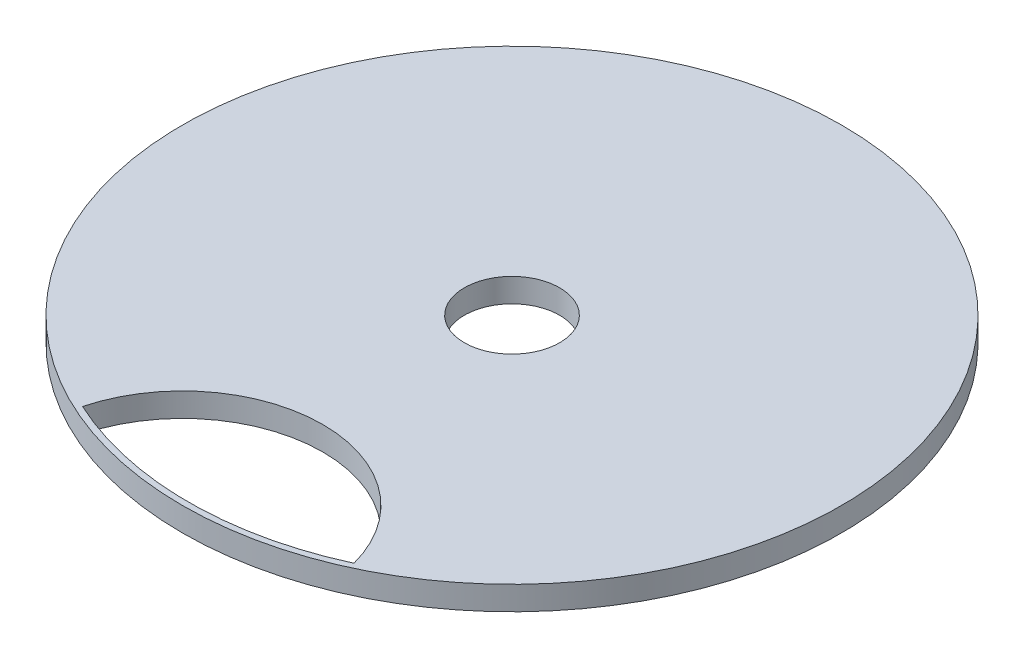
from build123d import *

# Parameters (mm, degrees)
SKETCH1_R           = 41.5
SKETCH1_R_2         = 6
BOSS_EXTRUDE1_DEPTH = 3
CUT_EXTRUDE1_DEPTH  = 3


with BuildPart() as part:
    # Sketch1 → Boss-Extrude1 (new body)
    with BuildSketch(Plane(origin=(0, 0, 0), x_dir=(1, 0, 0), z_dir=(0, 1, 0))):
        with Locations(Location((0, 0, 0), (0, 0, 270))):  # turned: the seam where the file's is
            Circle(SKETCH1_R)
        with Locations(Location((0, 0, 0), (0, 0, 270))):  # turned: the seam where the file's is
            Circle(SKETCH1_R_2, mode=Mode.SUBTRACT)
    extrude(amount=BOSS_EXTRUDE1_DEPTH)

    # Sketch2 → Cut-Extrude1 (cut)
    with BuildSketch(Plane(origin=(0, 3, 0), x_dir=(1, 0, 0), z_dir=(0, 1, 0))):
        with BuildLine():
            ThreePointArc((17.091808736, -36.992331288), (0, -23.82377294), (-17.091808736, -36.992331288))
            ThreePointArc((-17.091808736, -36.992331288), (0, -40.75), (17.091808736, -36.992331288))
        make_face()
    extrude(amount=-CUT_EXTRUDE1_DEPTH, mode=Mode.SUBTRACT)


solid = part.part
